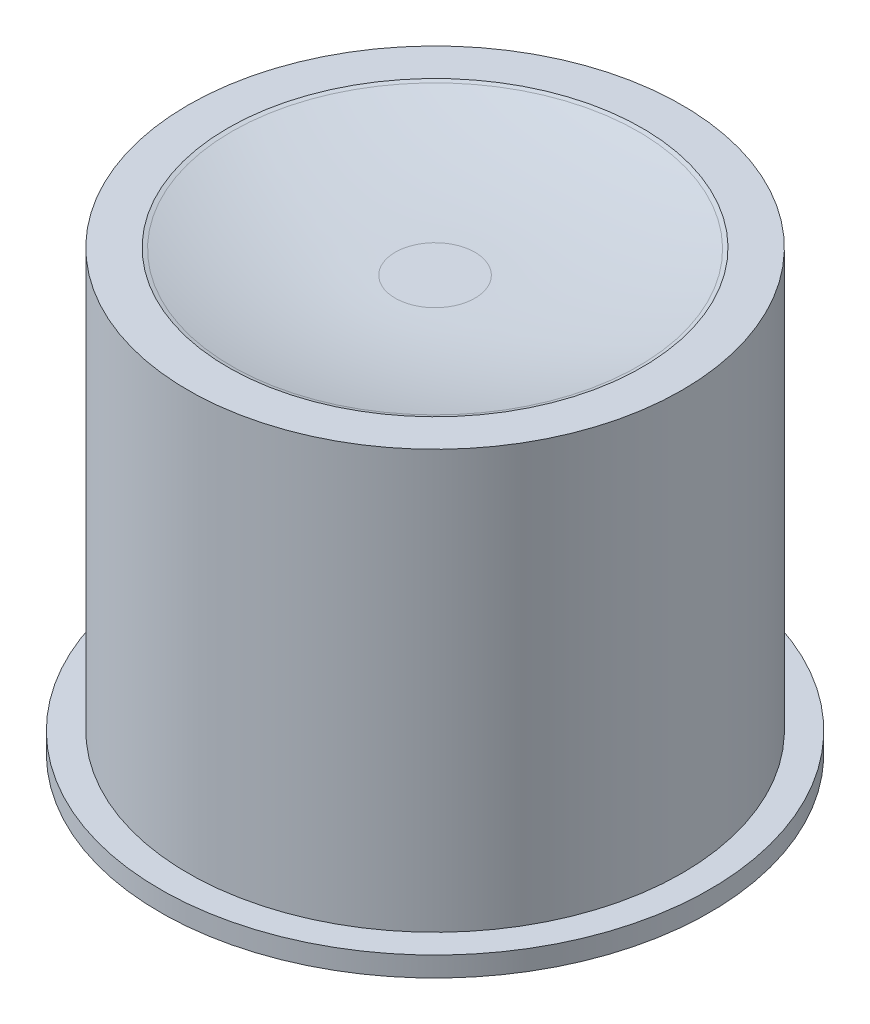
from build123d import *


with BuildPart() as part:
    # Sketch 183 → Revolve1 (revolve)
    with BuildSketch(Plane.XY):
        with BuildLine():
            Line((-5.2, 12), (-6.2, 12))
            Line((-6.2, 12), (-6.2, 1.5))
            Line((-6.2, 1.5), (-6.9, 1.5))
            Line((-6.9, 1.5), (-6.9, 1))
            Line((-6.9, 1), (-6.2, 1))
            Line((-6.2, 1), (-1.5, 1))
            Line((-1.5, 1), (-1.5, 0))
            Line((-1.5, 0), (0, 0))
            Line((0, 0), (0, 11.400347218))
            Line((0, 11.400347218), (-1, 11.400347218))
            ThreePointArc((-1, 11.400347218), (-3.071763766, 11.544109643), (-5.103815293, 11.972641231))
            Line((-5.103815293, 11.972641231), (-5.2, 12))
        make_face()
    revolve(axis=Axis((0, 11.400347218, 0), (0, -1, 0)))


solid = part.part
